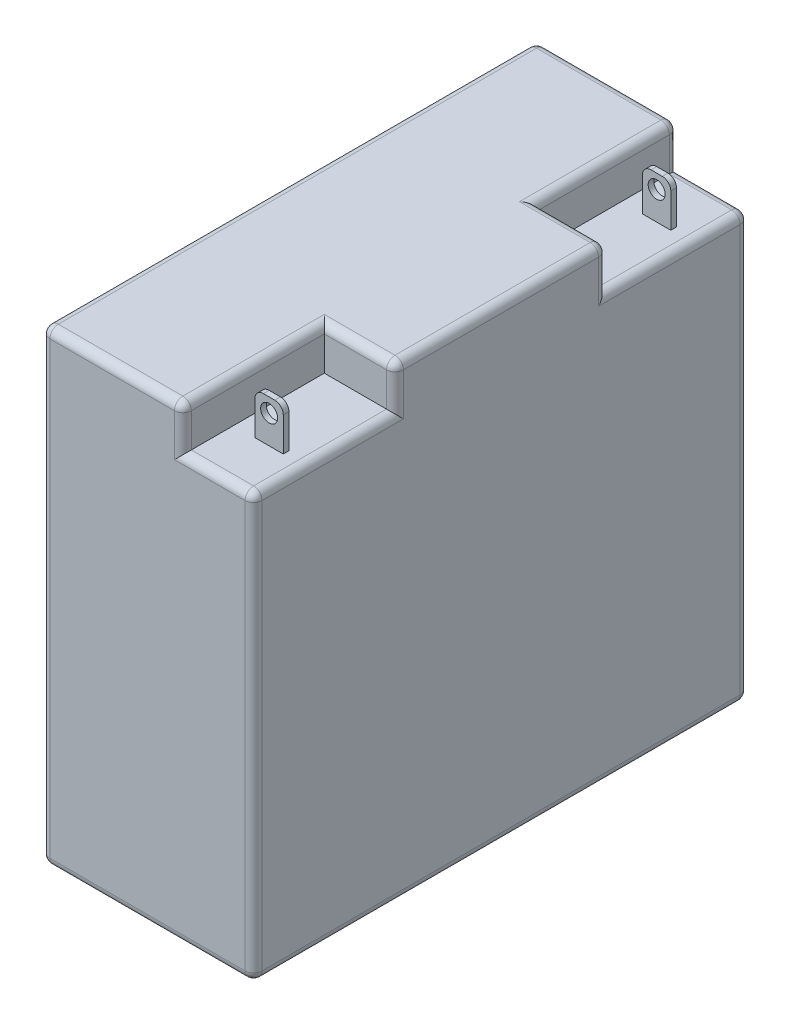
from build123d import *

# Parameters (mm, degrees)
SKETCH_1_W          = 75
SKETCH_1_H          = 175
EXTRUDE_1_DEPTH     = 165
SKETCH_2_W          = 25
SKETCH_2_H          = 50
CUT_EXTRUDE_1_DEPTH = 15
SKETCH_3_W          = 10
SKETCH_3_H          = 2
EXTRUDE_2_DEPTH     = 15
EXTRUDE_2_2_DEPTH   = 15
SKETCH_4_R          = 3
CUT_EXTRUDE_3_DEPTH = 200
FILLET_1_R          = 3
FILLET_2_R          = 3
FILLET_3_R          = 3


with BuildPart() as part:
    # Эскиз1 → Бобышка-Вытянуть1 (new body)
    with BuildSketch(Plane(origin=(0, 0, 0), x_dir=(1, 0, 0), z_dir=(0, 1, 0))):
        with Locations((37.5, 87.5)):
            Rectangle(SKETCH_1_W, SKETCH_1_H)
    extrude(amount=EXTRUDE_1_DEPTH)

    # Эскиз2 → Вырез-Вытянуть1 (cut)
    with BuildSketch(Plane(origin=(0, 165, 0), x_dir=(1, 0, 0), z_dir=(0, 1, 0))):
        with Locations((62.5, 150)):
            Rectangle(SKETCH_2_W, SKETCH_2_H)
        with Locations((62.5, 25)):
            Rectangle(SKETCH_2_W, SKETCH_2_H)
    extrude(amount=-CUT_EXTRUDE_1_DEPTH, mode=Mode.SUBTRACT)

    # Скругление3
    fillet_3_edges = [part.edges().sort_by_distance(p)[0] for p in [
        (75, 165, -87.5),
        (25, 165, -175),
        (75, 75, -175),
        (75, 75, 0),
        (75, 150, -150),
        (75, 157.5, -125),
        (62.5, 150, -175),
        (50, 157.5, -175),
        (50, 165, -150),
        (62.5, 165, -125),
        (75, 150, -25),
        (75, 157.5, -50),
        (62.5, 150, 0),
        (50, 157.5, 0),
        (62.5, 165, -50),
        (50, 165, -25),
        (0, 165, -87.5),
        (37.5, 0, -175),
        (75, 0, -87.5),
        (37.5, 0, 0),
        (0, 0, -87.5),
        (25, 165, 0),
        (0, 82.5, -175),
        (0, 82.5, 0),
    ]]
    fillet(fillet_3_edges, radius=FILLET_3_R)


with BuildPart() as body_2:
    # Эскиз3 → Бобышка-Вытянуть2 (new body)
    with BuildSketch(Plane(origin=(0, 150, 0), x_dir=(1, 0, 0), z_dir=(0, 1, 0))):
        with Locations((62.5, 156)):
            Rectangle(SKETCH_3_W, SKETCH_3_H)
    extrude(amount=EXTRUDE_2_DEPTH)


with BuildPart() as body_3:
    # Эскиз3 → Extrude 2 2 (new body)
    with BuildSketch(Plane(origin=(0, 150, 0), x_dir=(1, 0, 0), z_dir=(0, 1, 0))):
        with Locations((62.5, 19)):
            Rectangle(SKETCH_3_W, SKETCH_3_H)
    extrude(amount=EXTRUDE_2_2_DEPTH)


with BuildPart() as cut_extrude_3_tool:
    # Эскиз4 → Вырез-Вытянуть3 (new body)
    with BuildSketch(Plane.XY.offset(-18)):
        with Locations((62.5, 160)):
            Circle(SKETCH_4_R)
    extrude(amount=-CUT_EXTRUDE_3_DEPTH)


with BuildPart() as body_3_1:
    add(body_3.part)

    # Вырез-Вытянуть3: cut by cut_extrude_3_tool
    add(cut_extrude_3_tool.part, mode=Mode.SUBTRACT)

    # Скругление1
    fillet_1_edges = [body_3_1.edges().sort_by_distance(p)[0] for p in [
        (67.5, 165, -19),
        (57.5, 165, -19),
    ]]
    fillet(fillet_1_edges, radius=FILLET_1_R)


with BuildPart() as body_2_1:
    add(body_2.part)

    # Вырез-Вытянуть3: cut by cut_extrude_3_tool
    add(cut_extrude_3_tool.part, mode=Mode.SUBTRACT)

    # Скругление2
    fillet_2_edges = [body_2_1.edges().sort_by_distance(p)[0] for p in [
        (67.5, 165, -156),
        (57.5, 165, -156),
    ]]
    fillet(fillet_2_edges, radius=FILLET_2_R)


solid = Compound([part.part, body_3_1.part, body_2_1.part])
